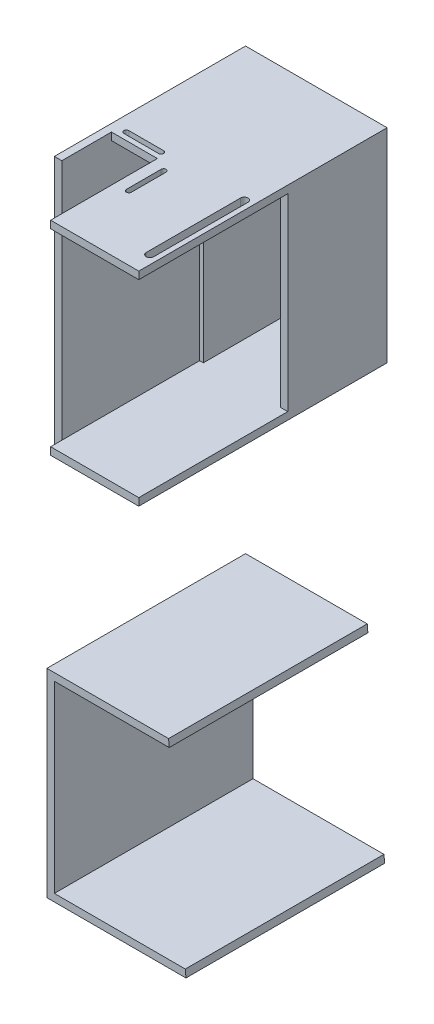
from build123d import *

# Parameters (mm, degrees)
EXTRUDE_1_DEPTH      = 100
EXTRUDE_2_DEPTH      = 80
SKETCH_4_W           = 23
SKETCH_4_H           = 23
CUT_EXTRUDE_5_DEPTH  = 80
EXTRUDE_4_DEPTH      = 77
SKETCH_7_W           = 18.5
SKETCH_7_H           = 98.970851358
CUT_EXTRUDE_8_DEPTH  = 50
SKETCH_5_W           = 4
SKETCH_5_H           = 100
CUT_EXTRUDE_9_DEPTH  = 105
SKETCH_8_W           = 20
SKETCH_8_H           = 20
CUT_EXTRUDE_11_DEPTH = 14
SKETCH_12_W          = 3
SKETCH_12_H          = 40
EXTRUDE_8_DEPTH      = 79
SKETCH_14_W          = 1.5
SKETCH_14_H          = 77
EXTRUDE_11_DEPTH     = 79
SKETCH_15_W          = 37
SKETCH_15_H          = 76
CUT_EXTRUDE_12_DEPTH = 46
SKETCH_16_W          = 21.5
SKETCH_16_H          = 23
CUT_EXTRUDE_13_DEPTH = 10
SKETCH_1_7_W         = 24.5
SKETCH_1_7_H         = 20
EXTRUDE_12_DEPTH     = 77
SKETCH_7_3_W         = 18.5
SKETCH_7_3_H         = 98.970851358
CUT_EXTRUDE_14_DEPTH = 20
SKETCH_1_8_W         = 18.5
SKETCH_1_8_H         = 17
CUT_EXTRUDE_15_DEPTH = 17
EXTRUDE_START        = -3
SKETCH_19_W          = 1.5
SKETCH_19_H          = 23
EXTRUDE_13_DEPTH     = 3
SKETCH_20_W          = 1.5
SKETCH_20_H          = 1
EXTRUDE_14_DEPTH     = 100


with BuildPart() as part:
    # 스케치1 → 보스-돌출1 (new body)
    with BuildSketch(Plane.XY):
        Polygon((0, 0), (61, 0), (60.853658537, 3), (3, 3), (3, 79), (57.146341463, 79), (57, 82), (0, 82), align=None)
    extrude(amount=EXTRUDE_1_DEPTH)

    # 스케치4 → 컷-돌출5 (cut)
    with BuildSketch(Plane(origin=(0, 82, 0), x_dir=(1, 0, 0), z_dir=(0, 1, 0))):
        with Locations((11.5, -88.5)):
            Rectangle(SKETCH_4_W, SKETCH_4_H)
    extrude(amount=-CUT_EXTRUDE_5_DEPTH, mode=Mode.SUBTRACT)

    # 스케치1<5> → 보스-돌출4 (add)
    with BuildSketch(Plane.XY):
        Polygon((3, 0), (0, 0), (0, -20), (24.5, -20), (24.5, 0), (21.5, 0), (21.5, -17), (3, -17), align=None)
    extrude(amount=EXTRUDE_4_DEPTH)

    # 스케치7 → 컷-돌출8 (cut)
    with BuildSketch(Plane.XZ.offset(20)):
        with Locations((12.25, 59.485425679)):
            Rectangle(SKETCH_7_W, SKETCH_7_H)
    extrude(amount=-CUT_EXTRUDE_8_DEPTH, mode=Mode.SUBTRACT)

    # 스케치5 → 컷-돌출9 (cut)
    with BuildSketch(Plane(origin=(0, 82, 0), x_dir=(1, 0, 0), z_dir=(0, 1, 0))):
        with Locations((59, -50)):
            Rectangle(SKETCH_5_W, SKETCH_5_H)
    extrude(amount=-CUT_EXTRUDE_9_DEPTH, mode=Mode.SUBTRACT)

    # 스케치8 → 컷-돌출11 (cut)
    with BuildSketch(Plane(origin=(0, 82, 0), x_dir=(1, 0, 0), z_dir=(0, 1, 0))):
        with BuildLine():
            Line((6, -53), (20, -53))
            ThreePointArc((20, -53), (21, -54), (20, -55))
            Line((20, -55), (6, -55))
            ThreePointArc((6, -55), (5, -54), (6, -53))
        make_face()
        with BuildLine():
            Line((26, -74), (26, -60))
            ThreePointArc((26, -60), (27, -59), (28, -60))
            Line((28, -60), (28, -74))
            ThreePointArc((28, -74), (27, -75), (26, -74))
        make_face()
        with Locations((13, -67)):
            Rectangle(SKETCH_8_W, SKETCH_8_H)
        with BuildLine():
            Line((52, -92), (52, -54))
            ThreePointArc((52, -54), (53.5, -52.5), (55, -54))
            Line((55, -54), (55, -92))
            ThreePointArc((55, -92), (53.5, -93.5), (52, -92))
        make_face()
    extrude(amount=-CUT_EXTRUDE_11_DEPTH, mode=Mode.SUBTRACT)

    # 스케치12 → 보스-돌출8 (add)
    with BuildSketch(Plane(origin=(0, 82, 0), x_dir=(1, 0, 0), z_dir=(0, 1, 0))):
        with Locations((55.5, -20)):
            Rectangle(SKETCH_12_W, SKETCH_12_H)
    extrude(amount=-EXTRUDE_8_DEPTH)

    # 스케치14 → 보스-돌출11 (add)
    with BuildSketch(Plane(origin=(0, 3, 0), x_dir=(1, 0, 0), z_dir=(0, 1, 0))):
        with Locations((22.25, -38.5)):
            Rectangle(SKETCH_14_W, SKETCH_14_H)
    extrude(amount=EXTRUDE_11_DEPTH)

    # 스케치15 → 컷-돌출12 (cut)
    with BuildSketch(Plane(origin=(57, 0, 0), x_dir=(0, 0, -1), z_dir=(1, 0, 0))):
        with Locations((-58.5, 41)):
            Rectangle(SKETCH_15_W, SKETCH_15_H)
    extrude(amount=-CUT_EXTRUDE_12_DEPTH, mode=Mode.SUBTRACT)

    # 스케치16 → 컷-돌출13 (cut)
    with BuildSketch(Plane(origin=(0, 3, 0), x_dir=(1, 0, 0), z_dir=(0, 1, 0))):
        with Locations((10.75, -88.5)):
            Rectangle(SKETCH_16_W, SKETCH_16_H)
    extrude(amount=-CUT_EXTRUDE_13_DEPTH, mode=Mode.SUBTRACT)

    # 스케치1<7> → 보스-돌출12 (add)
    with BuildSketch(Plane.XY):
        with Locations((12.25, -10)):
            Rectangle(SKETCH_1_7_W, SKETCH_1_7_H)
    extrude(amount=EXTRUDE_12_DEPTH)

    # 스케치7<3> → 컷-돌출14 (cut)
    with BuildSketch(Plane.XZ.offset(20)):
        with Locations((12.25, 59.485425679)):
            Rectangle(SKETCH_7_3_W, SKETCH_7_3_H)
    extrude(amount=-CUT_EXTRUDE_14_DEPTH, mode=Mode.SUBTRACT)

    # 스케치1<8> → 컷-돌출15 (cut)
    with BuildSketch(Plane.XY):
        with Locations((12.25, -8.5)):
            Rectangle(SKETCH_1_8_W, SKETCH_1_8_H)
    extrude(amount=CUT_EXTRUDE_15_DEPTH, mode=Mode.SUBTRACT)

    # 스케치19 → 보스-돌출13 (add)
    with BuildSketch(Plane(origin=(0, 82, 0), x_dir=(1, 0, 0), z_dir=(0, 1, 0)).offset(EXTRUDE_START)):
        with Locations((22.25, -88.5)):
            Rectangle(SKETCH_19_W, SKETCH_19_H)
    extrude(amount=EXTRUDE_13_DEPTH)

    # 스케치20 → 보스-돌출14 (add)
    with BuildSketch(Plane.XY.offset(100)):
        with Locations((22.25, 2.5)):
            Rectangle(SKETCH_20_W, SKETCH_20_H)
    extrude(amount=-EXTRUDE_14_DEPTH)


with BuildPart() as body_2:
    # 스케치1<3> → 보스-돌출2 (new body)
    with BuildSketch(Plane.XY):
        Polygon((0, -95.03327627), (49, -95.03327627), (49.2625, -98.03327627), (3, -98.03327627), (3, -172.03327627), (55.7375, -172.03327627), (56, -175.03327627), (0, -175.03327627), align=None)
    extrude(amount=EXTRUDE_2_DEPTH)


solid = Compound([part.part, body_2.part])
